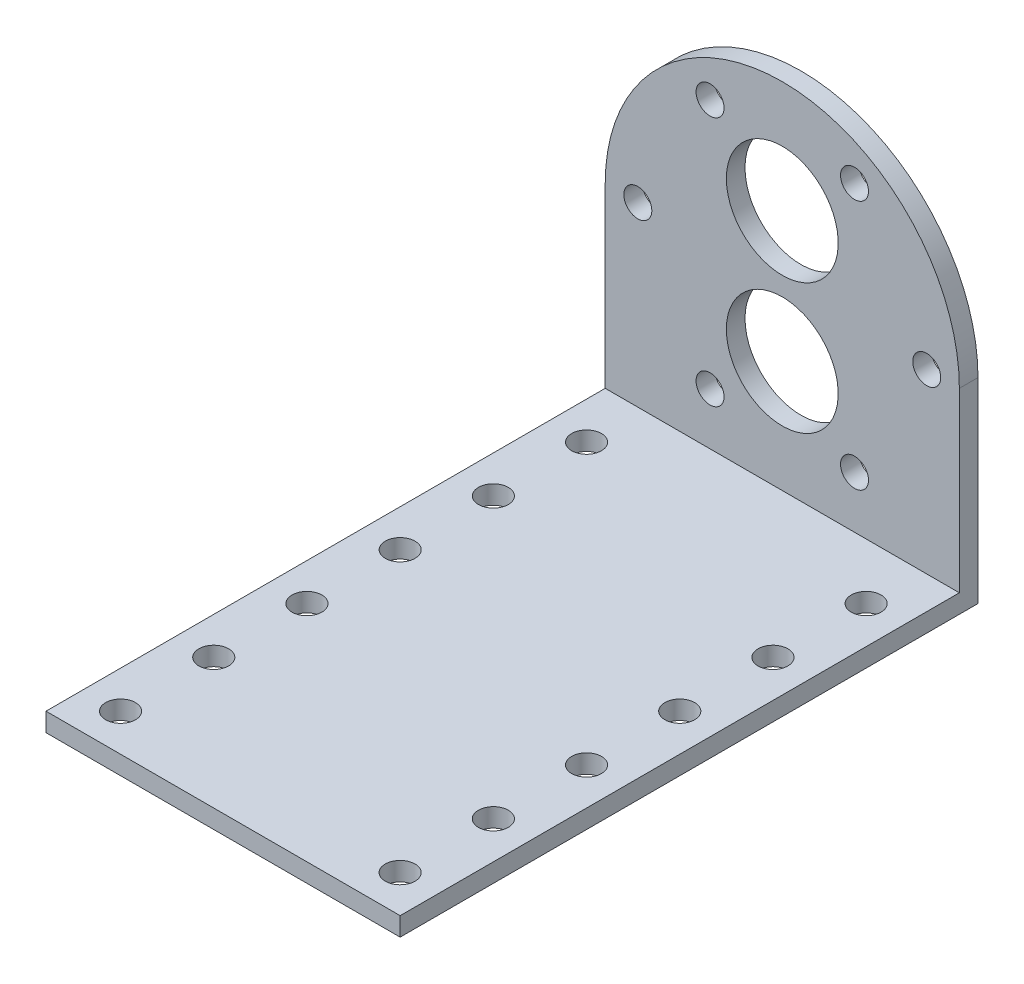
from build123d import *

# Parameters (mm, degrees)
EXTRUDE_1_DEPTH     = 2
SKETCH_2_W          = 38
SKETCH_2_H          = 2
EXTRUDE_2_DEPTH     = 60
SKETCH_3_R          = 1.6
CUT_EXTRUDE_1_DEPTH = 2
SKETCH_4_R          = 6
SKETCH_4_R_2        = 1.5
CUT_EXTRUDE_3_DEPTH = 2


with BuildPart() as part:
    # ｽｹｯﾁ1 → ﾎﾞｽ - 押し出し1 (new body)
    with BuildSketch(Plane.XY):
        with BuildLine():
            Line((-19, 0), (-19, -21))
            Line((-19, -21), (19, -21))
            Line((19, -21), (19, 0))
            ThreePointArc((19, 0), (0, 19), (-19, 0))
        make_face()
    extrude(amount=EXTRUDE_1_DEPTH)

    # ｽｹｯﾁ2 → ﾎﾞｽ - 押し出し2 (add)
    with BuildSketch(Plane.XY.offset(2)):
        with Locations((0, -20)):
            Rectangle(SKETCH_2_W, SKETCH_2_H)
    extrude(amount=EXTRUDE_2_DEPTH)

    # ｽｹｯﾁ3 → ｶｯﾄ - 押し出し1 (cut)
    with BuildSketch(Plane(origin=(0, -19, 0), x_dir=(1, 0, 0), z_dir=(0, 1, 0))):
        with Locations(Location((-15, -8, 0), (0, 0, 270))):  # turned: the seam where the file's is
            Circle(SKETCH_3_R)
        with Locations(Location((-15, -18, 0), (0, 0, 270))):  # turned: the seam where the file's is
            Circle(SKETCH_3_R)
        with Locations(Location((-15, -38, 0), (0, 0, 270))):  # turned: the seam where the file's is
            Circle(SKETCH_3_R)
        with Locations(Location((-15, -28, 0), (0, 0, 270))):  # turned: the seam where the file's is
            Circle(SKETCH_3_R)
        with Locations(Location((-15, -48, 0), (0, 0, 270))):  # turned: the seam where the file's is
            Circle(SKETCH_3_R)
        with Locations(Location((15, -8, 0), (0, 0, 270))):  # turned: the seam where the file's is
            Circle(SKETCH_3_R)
        with Locations(Location((15, -18, 0), (0, 0, 270))):  # turned: the seam where the file's is
            Circle(SKETCH_3_R)
        with Locations(Location((15, -28, 0), (0, 0, 270))):  # turned: the seam where the file's is
            Circle(SKETCH_3_R)
        with Locations(Location((15, -38, 0), (0, 0, 270))):  # turned: the seam where the file's is
            Circle(SKETCH_3_R)
        with Locations(Location((15, -48, 0), (0, 0, 270))):  # turned: the seam where the file's is
            Circle(SKETCH_3_R)
        with Locations(Location((-15, -58, 0), (0, 0, 270))):  # turned: the seam where the file's is
            Circle(SKETCH_3_R)
        with Locations(Location((15, -58, 0), (0, 0, 270))):  # turned: the seam where the file's is
            Circle(SKETCH_3_R)
    extrude(amount=-CUT_EXTRUDE_1_DEPTH, mode=Mode.SUBTRACT)

    # ｽｹｯﾁ4 → ｶｯﾄ - 押し出し3 (cut)
    with BuildSketch(Plane(origin=(0, 0, 0), x_dir=(-1, 0, 0), z_dir=(0, 0, -1))):
        with Locations((0, 7)):
            Circle(SKETCH_4_R)
        with Locations((0, -7)):
            Circle(SKETCH_4_R)
        with Locations((-7.75, 13.423393759)):
            Circle(SKETCH_4_R_2)
        with Locations((-15.5, 0)):
            Circle(SKETCH_4_R_2)
        with Locations((15.5, 0)):
            Circle(SKETCH_4_R_2)
        with Locations((7.75, 13.423393759)):
            Circle(SKETCH_4_R_2)
        with Locations((7.75, -13.423393759)):
            Circle(SKETCH_4_R_2)
        with Locations((-7.75, -13.423393759)):
            Circle(SKETCH_4_R_2)
    extrude(amount=-CUT_EXTRUDE_3_DEPTH, mode=Mode.SUBTRACT)


solid = part.part
